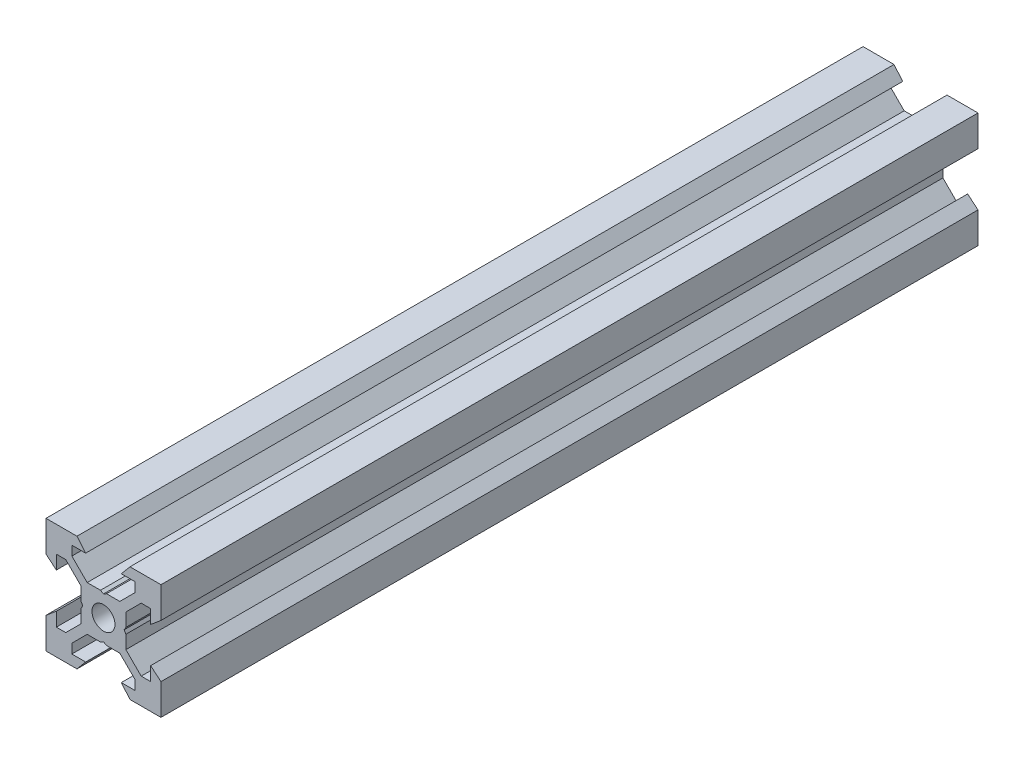
from build123d import *

# Parameters (mm, degrees)
SKETCH1_R           = 2
BOSS_EXTRUDE1_DEPTH = 71.075


with BuildPart() as part:
    # Sketch1 → Boss-Extrude1 (new body, symmetric)
    with BuildSketch(Plane.XY):
        Polygon((10, 10), (10, 4.610379336), (8.2, 3.1), (8.2, 5.5), (6.560660172, 5.5), (3.9, 2.839339828), (3.9, 0.519615242), (3.6, 0), (3.9, -0.519615242), (3.9, -2.839339828), (6.560660172, -5.5), (8.2, -5.5), (8.2, -3.1), (10, -4.610379336), (10, -10), (4.610379336, -10), (3.1, -8.2), (5.5, -8.2), (5.5, -6.560660172), (2.839339828, -3.9), (0.519615242, -3.9), (0, -3.6), (-0.519615242, -3.9), (-2.839339828, -3.9), (-5.5, -6.560660172), (-5.5, -8.2), (-3.1, -8.2), (-4.610379336, -10), (-10, -10), (-10, -4.610379336), (-8.2, -3.1), (-8.2, -5.5), (-6.560660172, -5.5), (-3.9, -2.839339828), (-3.9, -0.519615242), (-3.6, 0), (-3.9, 0.519615242), (-3.9, 2.839339828), (-6.560660172, 5.5), (-8.2, 5.5), (-8.2, 3.1), (-10, 4.610379336), (-10, 10), (-4.610379336, 10), (-3.1, 8.2), (-5.5, 8.2), (-5.5, 6.560660172), (-2.839339828, 3.9), (-0.519615242, 3.9), (0, 3.6), (0.519615242, 3.9), (2.839339828, 3.9), (5.5, 6.560660172), (5.5, 8.2), (3.1, 8.2), (4.610379336, 10), align=None)
        Circle(SKETCH1_R, mode=Mode.SUBTRACT)
    extrude(amount=BOSS_EXTRUDE1_DEPTH, both=True)


solid = part.part
